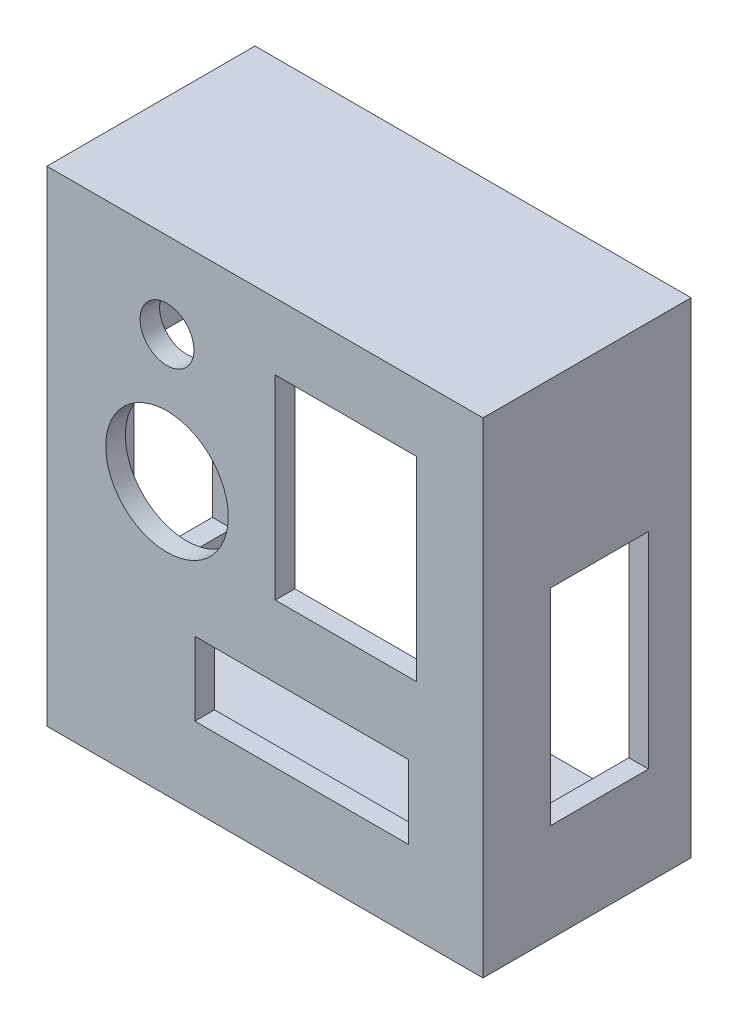
from build123d import *

# Parameters (mm, degrees)
SKETCH1_W           = 128.5875
SKETCH1_H           = 144.4625
BOSS_EXTRUDE1_DEPTH = 61.07176
SHELL1_T            = 6.35
SKETCH2_R           = 8.73125
SKETCH2_R_2         = 19.84375
SKETCH2_W           = 45.72
SKETCH2_H           = 63.1825
SKETCH2_W_2         = 69.215
SKETCH2_H_2         = 23.8125
CUT_EXTRUDE1_DEPTH  = 126.344509202
SKETCH3_W           = 31.75
SKETCH3_H           = 66.675
CUT_EXTRUDE2_DEPTH  = 173.82051492


with BuildPart() as part:
    # Sketch1 → Boss-Extrude1 (new body)
    with BuildSketch(Plane.XY):
        Rectangle(SKETCH1_W, SKETCH1_H)
    extrude(amount=-BOSS_EXTRUDE1_DEPTH)

    # Shell1
    shell1_openings = [part.faces().sort_by_distance(p)[0] for p in [
        (0, 0, -61.07176),
    ]]
    offset(amount=SHELL1_T, openings=shell1_openings, kind=Kind.INTERSECTION)

    # Sketch2 → Cut-Extrude1 (cut, through all)
    with BuildSketch(Plane.XY.offset(6.35)):
        with Locations((-31.75, 50.8)):
            Circle(SKETCH2_R)
        with Locations((-31.75, 9.525)):
            Circle(SKETCH2_R_2)
        with Locations((26.19375, 25.4)):
            Rectangle(SKETCH2_W, SKETCH2_H)
        with Locations((11.90625, -41.275)):
            Rectangle(SKETCH2_W_2, SKETCH2_H_2)
    extrude(amount=-CUT_EXTRUDE1_DEPTH, mode=Mode.SUBTRACT)

    # Sketch3 → Cut-Extrude2 (cut, through all)
    with BuildSketch(Plane(origin=(70.64375, 0, 0), x_dir=(0, 0, -1), z_dir=(1, 0, 0))):
        with Locations((31.39694, -13.43025)):
            Rectangle(SKETCH3_W, SKETCH3_H)
    extrude(amount=-CUT_EXTRUDE2_DEPTH, mode=Mode.SUBTRACT)


solid = part.part
